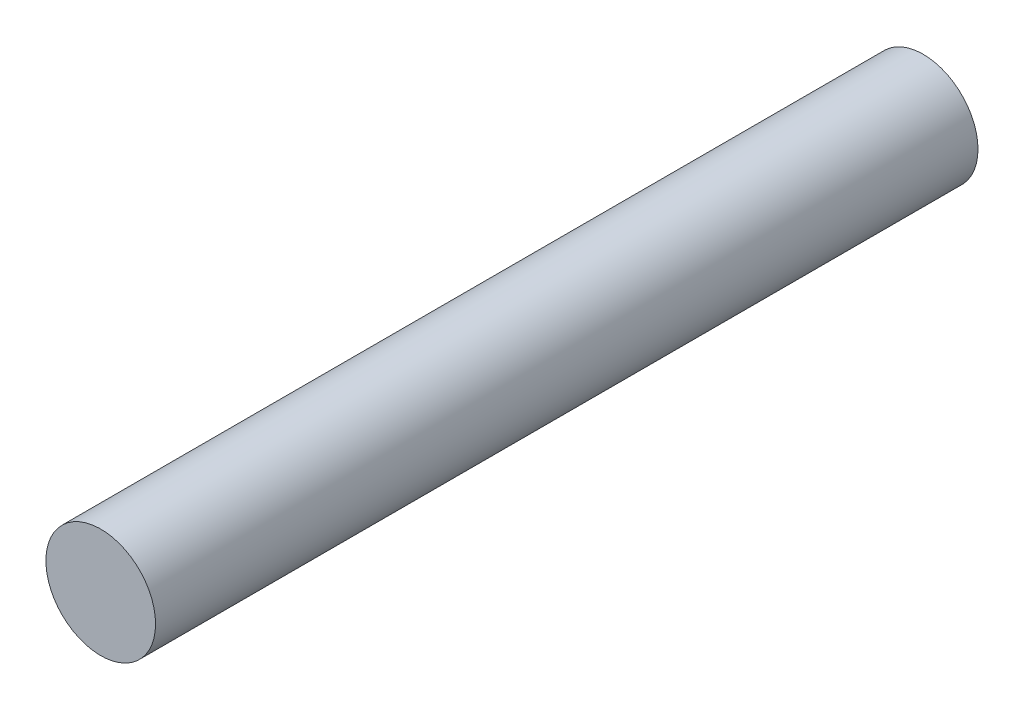
from build123d import *

# Parameters (mm, degrees)
SKETCH1_R           = 4
BOSS_EXTRUDE1_DEPTH = 60


with BuildPart() as part:
    # Sketch1 → Boss-Extrude1 (new body)
    with BuildSketch(Plane.XY):
        Circle(SKETCH1_R)
    extrude(amount=BOSS_EXTRUDE1_DEPTH)


solid = part.part
